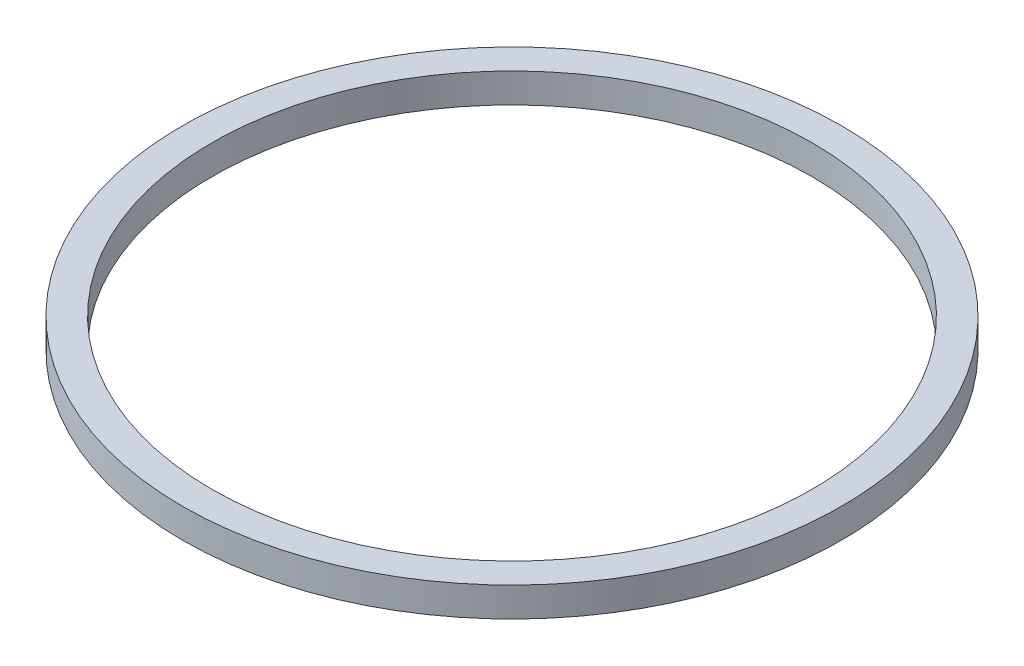
from build123d import *

# Parameters (mm, degrees)
SKETCH_1_W = 2.5
SKETCH_1_H = 2.5


with BuildPart() as part:
    # 草图1 → 旋转1 (revolve)
    with BuildSketch(Plane.XY, mode=Mode.PRIVATE) as revolve_1_sk:
        with Locations((26.75, 1.25)):
            Rectangle(SKETCH_1_W, SKETCH_1_H)
    revolve(revolve_1_sk.sketch.rotate(Axis((0, 77.144142266, 0), (0, -1, 0)), 90), axis=Axis((0, 77.144142266, 0), (0, -1, 0)))  # turned: the seam where the file's is


solid = part.part
